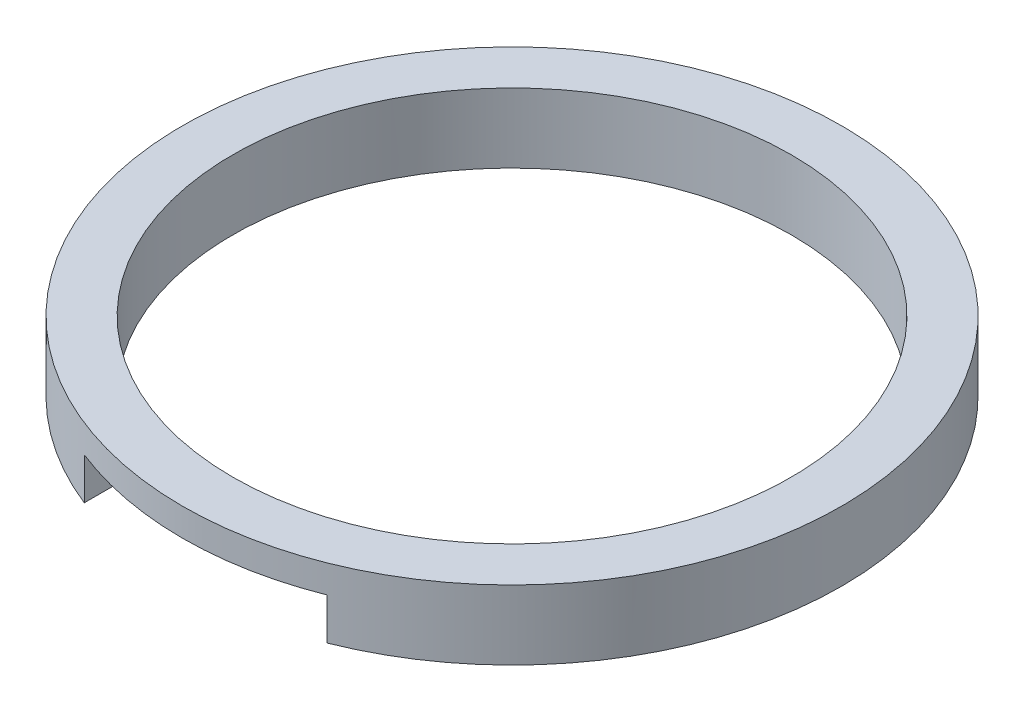
from build123d import *

# Parameters (mm, degrees)
SKETCH1_R           = 9.5
BOSS_EXTRUDE1_DEPTH = 2
SKETCH2_R           = 8.05
CUT_EXTRUDE1_DEPTH  = 3
CUT_EXTRUDE2_DEPTH  = 1.2


with BuildPart() as part:
    # Sketch1 → Boss-Extrude1 (new body)
    with BuildSketch(Plane(origin=(0, 0, 0), x_dir=(1, 0, 0), z_dir=(0, 1, 0))):
        Circle(SKETCH1_R)
    extrude(amount=BOSS_EXTRUDE1_DEPTH)

    # Sketch2 → Cut-Extrude1 (cut, through all)
    with BuildSketch(Plane(origin=(0, 2, 0), x_dir=(1, 0, 0), z_dir=(0, 1, 0))):
        Circle(SKETCH2_R)
    extrude(amount=-CUT_EXTRUDE1_DEPTH, mode=Mode.SUBTRACT)

    # Sketch3 → Cut-Extrude2 (cut)
    with BuildSketch(Plane.XZ):
        with BuildLine():
            Line((-3.5, 7.249310312), (-3.5, 8.831760866))
            ThreePointArc((-3.5, 8.831760866), (0, 9.5), (3.5, 8.831760866))
            Line((3.5, 8.831760866), (3.5, 7.249310312))
            ThreePointArc((3.5, 7.249310312), (0, 8.05), (-3.5, 7.249310312))
        make_face()
    extrude(amount=-CUT_EXTRUDE2_DEPTH, mode=Mode.SUBTRACT)


solid = part.part
